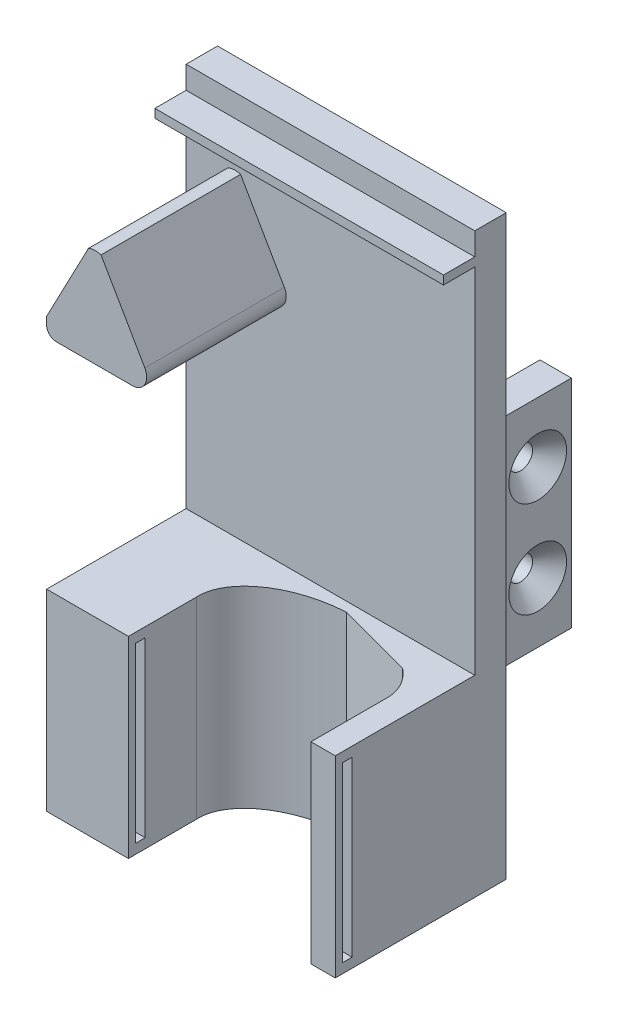
from build123d import *

# Parameters (mm, degrees)
SKETCH1_W                                       = 60
SKETCH1_H                                       = 120
BOSS_EXTRUDE1_DEPTH                             = 6.54
SKETCH10_W                                      = 6.54
SKETCH10_H                                      = 45
BOSS_EXTRUDE5_DEPTH                             = 17
SKETCH17_W                                      = 60
SKETCH17_H                                      = 40
BOSS_EXTRUDE6_DEPTH                             = 29
CUT_EXTRUDE1_REACH                              = 42
CUT_EXTRUDE2_REACH                              = 54.54
SKETCH21_W                                      = 37.9445377
SKETCH21_H                                      = 40
SKETCH23_W                                      = 2
SKETCH23_H                                      = 36
CUT_EXTRUDE3_DEPTH                              = 9
SKETCH24_W                                      = 2
SKETCH24_H                                      = 36
CUT_EXTRUDE4_DEPTH                              = 9
CSK_FOR_M3_FLAT_HEAD_MACHINE_SCREW4_D           = 4.93
CSK_FOR_M3_FLAT_HEAD_MACHINE_SCREW4_DEPTH       = 6.54
CSK_FOR_M3_FLAT_HEAD_MACHINE_SCREW4_CSINK_D     = 12
CSK_FOR_M3_FLAT_HEAD_MACHINE_SCREW4_CSINK_ANGLE = 90
CSK_FOR_M3_FLAT_HEAD_MACHINE_SCREW5_D           = 4.93
CSK_FOR_M3_FLAT_HEAD_MACHINE_SCREW5_DEPTH       = 6.54
CSK_FOR_M3_FLAT_HEAD_MACHINE_SCREW5_CSINK_D     = 12
CSK_FOR_M3_FLAT_HEAD_MACHINE_SCREW5_CSINK_ANGLE = 90
BOSS_EXTRUDE8_DEPTH                             = 29
SKETCH36_W                                      = 60
SKETCH36_H                                      = 1.8
BOSS_EXTRUDE9_DEPTH                             = 6.5
FILLET1_R                                       = 3
FILLET2_R                                       = 2


with BuildPart() as part:
    # Sketch1 → Boss-Extrude1 (new body)
    with BuildSketch(Plane.XY):
        Rectangle(SKETCH1_W, SKETCH1_H)
    extrude(amount=BOSS_EXTRUDE1_DEPTH)

    # Sketch10 → Boss-Extrude5 (add)
    with BuildSketch(Plane(origin=(0, 0, 0), x_dir=(-1, 0, 0), z_dir=(0, 0, -1))):
        with Locations((23.27, -2.5)):
            Rectangle(SKETCH10_W, SKETCH10_H)
        with Locations((-23.27, -2.5)):
            Rectangle(SKETCH10_W, SKETCH10_H)
    extrude(amount=BOSS_EXTRUDE5_DEPTH)

    # Sketch17 → Boss-Extrude6 (add)
    with BuildSketch(Plane.XY.offset(6.54)):
        with Locations((0, -40)):
            Rectangle(SKETCH17_W, SKETCH17_H)
    extrude(amount=BOSS_EXTRUDE6_DEPTH)

    # Sketch18 → Cut-Extrude1 (cut, up to next)
    with BuildSketch(Plane(origin=(0, -20, 0), x_dir=(1, 0, 0), z_dir=(0, 1, 0)), mode=Mode.PRIVATE) as cut_extrude1_sk1:
        with BuildLine():
            Line((5.334966353, -8.526396136), (21.291300905, -12.825812438))
            add(Edge.make_bspline(
                [(5.334966353, -8.526396136), (-17.854714365, -9.780670981), (-12.49786254, -23.648890313), (-7.141010715, -37.517109645), (13.926544327, -30.768916863), (34.994099369, -24.020724082), (21.291300905, -12.825812438)],
                knots=[1.570796327, 1.570796327, 1.570796327, 3.340987112, 3.340987112, 5.111177898, 5.111177898, 6.881368684, 6.881368684, 6.881368684], degree=2, weights=[1, 0.633215673, 1, 0.633215673, 1, 0.633215673, 1]))
        make_face()
    cut_extrude1_tool1 = extrude(cut_extrude1_sk1.sketch, amount=-CUT_EXTRUDE1_REACH, mode=Mode.PRIVATE) & part.part
    add(cut_extrude1_tool1.solids().sort_by_distance((5.792514, -20, 20.554542))[0], mode=Mode.SUBTRACT)

    # Sketch21 → Cut-Extrude2 (cut, up to next)
    with BuildSketch(Plane.XY.offset(35.54), mode=Mode.PRIVATE) as cut_extrude2_sk1:
        with Locations((5.97226885, -40)):
            Rectangle(SKETCH21_W, SKETCH21_H)
    cut_extrude2_tool1 = extrude(cut_extrude2_sk1.sketch, amount=-CUT_EXTRUDE2_REACH, mode=Mode.PRIVATE) & part.part
    add(cut_extrude2_tool1.solids().sort_by_distance((5.972269, -40, 35.54))[0], mode=Mode.SUBTRACT)

    # Sketch23 → Cut-Extrude3 (cut)
    with BuildSketch(Plane(origin=(-13, 0, 0), x_dir=(0, 0, -1), z_dir=(1, 0, 0))):
        with Locations((-33.04, -40)):
            Rectangle(SKETCH23_W, SKETCH23_H)
    extrude(amount=-CUT_EXTRUDE3_DEPTH, mode=Mode.SUBTRACT)

    # Sketch24 → Cut-Extrude4 (cut)
    with BuildSketch(Plane.ZY.offset(-24.9445377)):
        with Locations((33.04, -40)):
            Rectangle(SKETCH24_W, SKETCH24_H)
    extrude(amount=-CUT_EXTRUDE4_DEPTH, mode=Mode.SUBTRACT)

    # CSK for M3 Flat Head Machine Screw4
    with Locations(Plane(origin=(26.54, -12.5, -10), x_dir=(0, 1, 0), z_dir=(1, 0, 0))):
        with Locations((0, 0), (20, 0)):
            CounterSinkHole(CSK_FOR_M3_FLAT_HEAD_MACHINE_SCREW4_D / 2, CSK_FOR_M3_FLAT_HEAD_MACHINE_SCREW4_CSINK_D / 2, depth=CSK_FOR_M3_FLAT_HEAD_MACHINE_SCREW4_DEPTH, counter_sink_angle=CSK_FOR_M3_FLAT_HEAD_MACHINE_SCREW4_CSINK_ANGLE)

    # CSK for M3 Flat Head Machine Screw5
    with Locations(Plane(origin=(-26.54, -12.5, -10), x_dir=(0, -1, 0), z_dir=(-1, 0, 0))):
        with Locations((0, 0), (-20, 0)):
            CounterSinkHole(CSK_FOR_M3_FLAT_HEAD_MACHINE_SCREW5_D / 2, CSK_FOR_M3_FLAT_HEAD_MACHINE_SCREW5_CSINK_D / 2, depth=CSK_FOR_M3_FLAT_HEAD_MACHINE_SCREW5_DEPTH, counter_sink_angle=CSK_FOR_M3_FLAT_HEAD_MACHINE_SCREW5_CSINK_ANGLE)

    # Sketch7 → Boss-Extrude8 (add)
    with BuildSketch(Plane.XY.offset(6.54)):
        with BuildLine():
            Line((-7, 25.533918981), (-18.684094898, 45.817285768))
            ThreePointArc((-18.684094898, 45.817285768), (-20, 46), (-21.294986864, 45.703352481))
            Line((-21.294986864, 45.703352481), (-30, 29.115374119))
            Line((-30, 29.115374119), (-30, 25.533918981))
            Line((-30, 25.533918981), (-7, 25.533918981))
        make_face()
    extrude(amount=BOSS_EXTRUDE8_DEPTH)

    # Sketch36 → Boss-Extrude9 (add)
    with BuildSketch(Plane.XY.offset(6.54)):
        with Locations((0, 54.4)):
            Rectangle(SKETCH36_W, SKETCH36_H)
    extrude(amount=BOSS_EXTRUDE9_DEPTH)

    # Fillet1
    fillet1_edges = [part.edges().sort_by_distance(p)[0] for p in [
        (-7, 25.533918981, 21.04),
    ]]
    fillet(fillet1_edges, radius=FILLET1_R)

    # Fillet2
    fillet2_edges = [part.edges().sort_by_distance(p)[0] for p in [
        (-30, 25.533918981, 21.04),
    ]]
    fillet(fillet2_edges, radius=FILLET2_R)


solid = part.part
